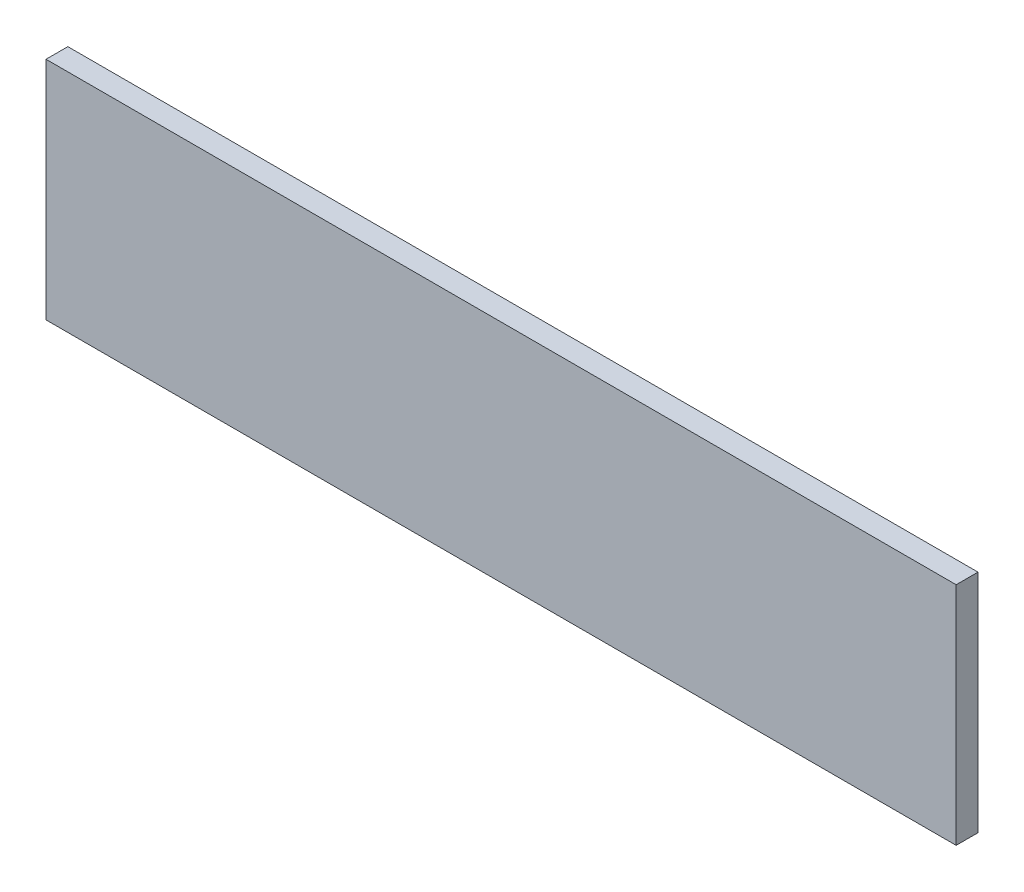
from build123d import *

# Parameters (mm, degrees)
ESQUISSE1_W        = 125
ESQUISSE1_H        = 31
BOSS_EXTRU_1_DEPTH = 3


with BuildPart() as part:
    # Esquisse1 → Boss.-Extru.1 (new body)
    with BuildSketch(Plane.XY):
        Rectangle(ESQUISSE1_W, ESQUISSE1_H)
    extrude(amount=BOSS_EXTRU_1_DEPTH)


solid = part.part
